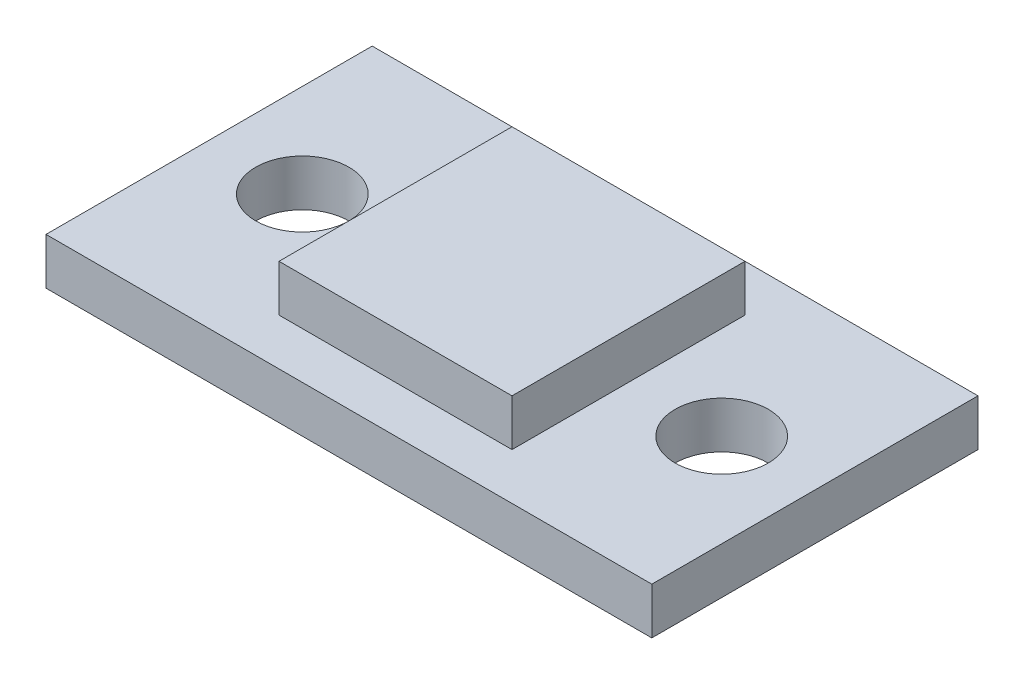
from build123d import *

# Parameters (mm, degrees)
ESQUISSE1_W        = 5
ESQUISSE1_H        = 5
BOSS_EXTRU_1_DEPTH = 1
ESQUISSE2_W        = 13
ESQUISSE2_H        = 7
ESQUISSE2_R        = 1
BOSS_EXTRU_2_DEPTH = 1


with BuildPart() as part:
    # Esquisse1 → Boss.-Extru.1 (new body)
    with BuildSketch(Plane(origin=(0, 0, 0), x_dir=(1, 0, 0), z_dir=(0, 1, 0))):
        Rectangle(ESQUISSE1_W, ESQUISSE1_H)
    extrude(amount=BOSS_EXTRU_1_DEPTH)

    # Esquisse2 → Boss.-Extru.2 (add)
    with BuildSketch(Plane.XZ):
        Rectangle(ESQUISSE2_W, ESQUISSE2_H)
        with Locations((4.5, 0)):
            Circle(ESQUISSE2_R, mode=Mode.SUBTRACT)
        with Locations((-4.5, 0)):
            Circle(ESQUISSE2_R, mode=Mode.SUBTRACT)
    extrude(amount=BOSS_EXTRU_2_DEPTH)


solid = part.part
